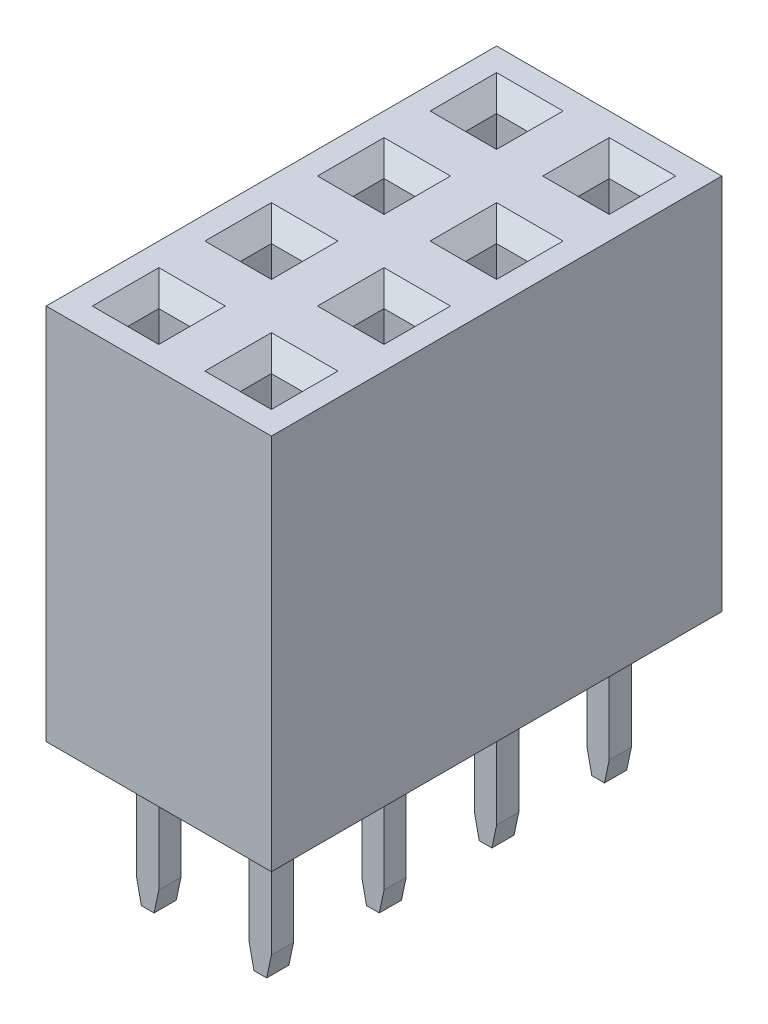
from build123d import *
from OCP.BRepFilletAPI import BRepFilletAPI_MakeChamfer

# Parameters (mm, degrees)
SKETCH_1_W                          = 2.54
SKETCH_1_H                          = 2.54
EXTRUDE_1_DEPTH                     = 8.51
SKETCH_4_W                          = 0.7
SKETCH_4_H                          = 0.7
CUT_EXTRUDE_1_DEPTH                 = 8.21
CHAMFER_3_SIZE                      = 0.4
SKETCH_2_W                          = 0.5
SKETCH_2_H                          = 0.5
EXTRUDE_2_DEPTH                     = 3.15
CHAMFER_2_SIZE                      = 0.5
CHAMFER_2_SIZE2                     = 0.106278281
PATTERN_LINEAR_1_COUNT              = 4
PATTERN_LINEAR_1_PITCH              = 2.54
PATTERN_LINEAR_1_COUNT_DIR2         = 2
PATTERN_LINEAR_1_PITCH_DIR2         = 2.54
CHAMFER_3_OF_PATTERN_LINEAR_1_SIZE  = 0.4
CHAMFER_2_OF_PATTERN_LINEAR_1_SIZE  = 0.5
CHAMFER_2_OF_PATTERN_LINEAR_1_SIZE2 = 0.106278281


with BuildPart() as part:
    # Эскиз1 → Бобышка-Вытянуть1 (new body)
    with BuildSketch(Plane(origin=(0, 0, 0), x_dir=(-1, 0, 0), z_dir=(0, 1, 0))):
        Rectangle(SKETCH_1_W, SKETCH_1_H)
    extrude_1 = extrude(amount=EXTRUDE_1_DEPTH)

    # Эскиз4 → Вырез-Вытянуть1 (cut)
    with BuildSketch(Plane(origin=(0, 8.51, 0), x_dir=(1, 0, 0), z_dir=(0, 1, 0))):
        Rectangle(SKETCH_4_W, SKETCH_4_H)
    cut_extrude_1 = extrude(amount=-CUT_EXTRUDE_1_DEPTH, mode=Mode.SUBTRACT)

    # Фаска3
    chamfer_3_edges = [part.edges().sort_by_distance(p)[0] for p in [
        (-0.35, 8.51, 0),
        (0, 8.51, 0.35),
        (0.35, 8.51, 0),
        (0, 8.51, -0.35),
    ]]
    chamfer(chamfer_3_edges, length=CHAMFER_3_SIZE)

    # Эскиз2 → Бобышка-Вытянуть2 (add)
    with BuildSketch(Plane(origin=(0, 0, 0), x_dir=(-1, 0, 0), z_dir=(0, 1, 0))):
        Rectangle(SKETCH_2_W, SKETCH_2_H)
    extrude_2 = extrude(amount=-EXTRUDE_2_DEPTH)

    # Фаска2: one chamfer whose edges measure the first distance from different faces: ONE call of the kernel's chamfer builder (chamfer() names one face for all edges)
    chamfer_2_edges_1 = [part.edges().sort_by_distance(p)[0] for p in [
        (-0.25, -3.15, 0),
    ]]
    chamfer_2_side_1 = [part.faces().sort_by_distance(p)[0] for p in [
        (-0.25, -1.575, 0),
    ]]
    chamfer_2_edges_2 = [part.edges().sort_by_distance(p)[0] for p in [
        (0.25, -3.15, 0),
    ]]
    chamfer_2_side_2 = [part.faces().sort_by_distance(p)[0] for p in [
        (0.25, -1.575, 0),
    ]]
    chamfer_2 = BRepFilletAPI_MakeChamfer(part.part.solid().wrapped)
    for e in chamfer_2_edges_1:
        chamfer_2.Add(CHAMFER_2_SIZE, CHAMFER_2_SIZE2, e.wrapped, chamfer_2_side_1[0].wrapped)  # the first distance lies on this face
    for e in chamfer_2_edges_2:
        chamfer_2.Add(CHAMFER_2_SIZE, CHAMFER_2_SIZE2, e.wrapped, chamfer_2_side_2[0].wrapped)  # the first distance lies on this face
    add(Compound.cast(chamfer_2.Shape()), mode=Mode.REPLACE)

    # Линейный массив1: Бобышка-Вытянуть1, Вырез-Вытянуть1, Extrude 2 4 × 2
    with Locations(*[(-j * PATTERN_LINEAR_1_PITCH_DIR2, 0, -i * PATTERN_LINEAR_1_PITCH) for i in range(PATTERN_LINEAR_1_COUNT) for j in range(PATTERN_LINEAR_1_COUNT_DIR2) if (i, j) != (0, 0)]):
        add(extrude_1)
        add(cut_extrude_1, mode=Mode.SUBTRACT)
        add(extrude_2)

    # Фаска3 of Линейный массив1
    chamfer_3_of_pattern_linear_1_edges = [part.edges().sort_by_distance(p)[0] for p in [
        (-2.89, 8.51, 0),
        (-2.54, 8.51, 0.35),
        (-2.19, 8.51, 0),
        (-2.54, 8.51, -0.35),
        (-0.35, 8.51, -2.54),
        (0, 8.51, -2.19),
        (0.35, 8.51, -2.54),
        (0, 8.51, -2.89),
        (-2.89, 8.51, -2.54),
        (-2.54, 8.51, -2.19),
        (-2.19, 8.51, -2.54),
        (-2.54, 8.51, -2.89),
        (-0.35, 8.51, -5.08),
        (0, 8.51, -4.73),
        (0.35, 8.51, -5.08),
        (0, 8.51, -5.43),
        (-2.89, 8.51, -5.08),
        (-2.54, 8.51, -4.73),
        (-2.19, 8.51, -5.08),
        (-2.54, 8.51, -5.43),
        (-0.35, 8.51, -7.62),
        (0, 8.51, -7.27),
        (0.35, 8.51, -7.62),
        (0, 8.51, -7.97),
        (-2.89, 8.51, -7.62),
        (-2.54, 8.51, -7.27),
        (-2.19, 8.51, -7.62),
        (-2.54, 8.51, -7.97),
    ]]
    chamfer(chamfer_3_of_pattern_linear_1_edges, length=CHAMFER_3_OF_PATTERN_LINEAR_1_SIZE)

    # Фаска2 of Линейный массив1: one chamfer whose edges measure the first distance from different faces: ONE call of the kernel's chamfer builder (chamfer() names one face for all edges)
    chamfer_2_of_pattern_linear_1_edges_1 = [part.edges().sort_by_distance(p)[0] for p in [
        (-2.79, -3.15, 0),
    ]]
    chamfer_2_of_pattern_linear_1_side_1 = [part.faces().sort_by_distance(p)[0] for p in [
        (-2.79, -1.575, 0),
    ]]
    chamfer_2_of_pattern_linear_1_edges_2 = [part.edges().sort_by_distance(p)[0] for p in [
        (-2.29, -3.15, 0),
    ]]
    chamfer_2_of_pattern_linear_1_side_2 = [part.faces().sort_by_distance(p)[0] for p in [
        (-2.29, -1.575, 0),
    ]]
    chamfer_2_of_pattern_linear_1_edges_3 = [part.edges().sort_by_distance(p)[0] for p in [
        (-0.25, -3.15, -2.54),
    ]]
    chamfer_2_of_pattern_linear_1_side_3 = [part.faces().sort_by_distance(p)[0] for p in [
        (-0.25, -1.575, -2.54),
    ]]
    chamfer_2_of_pattern_linear_1_edges_4 = [part.edges().sort_by_distance(p)[0] for p in [
        (0.25, -3.15, -2.54),
    ]]
    chamfer_2_of_pattern_linear_1_side_4 = [part.faces().sort_by_distance(p)[0] for p in [
        (0.25, -1.575, -2.54),
    ]]
    chamfer_2_of_pattern_linear_1_edges_5 = [part.edges().sort_by_distance(p)[0] for p in [
        (-2.79, -3.15, -2.54),
    ]]
    chamfer_2_of_pattern_linear_1_side_5 = [part.faces().sort_by_distance(p)[0] for p in [
        (-2.79, -1.575, -2.54),
    ]]
    chamfer_2_of_pattern_linear_1_edges_6 = [part.edges().sort_by_distance(p)[0] for p in [
        (-2.29, -3.15, -2.54),
    ]]
    chamfer_2_of_pattern_linear_1_side_6 = [part.faces().sort_by_distance(p)[0] for p in [
        (-2.29, -1.575, -2.54),
    ]]
    chamfer_2_of_pattern_linear_1_edges_7 = [part.edges().sort_by_distance(p)[0] for p in [
        (-0.25, -3.15, -5.08),
    ]]
    chamfer_2_of_pattern_linear_1_side_7 = [part.faces().sort_by_distance(p)[0] for p in [
        (-0.25, -1.575, -5.08),
    ]]
    chamfer_2_of_pattern_linear_1_edges_8 = [part.edges().sort_by_distance(p)[0] for p in [
        (0.25, -3.15, -5.08),
    ]]
    chamfer_2_of_pattern_linear_1_side_8 = [part.faces().sort_by_distance(p)[0] for p in [
        (0.25, -1.575, -5.08),
    ]]
    chamfer_2_of_pattern_linear_1_edges_9 = [part.edges().sort_by_distance(p)[0] for p in [
        (-2.79, -3.15, -5.08),
    ]]
    chamfer_2_of_pattern_linear_1_side_9 = [part.faces().sort_by_distance(p)[0] for p in [
        (-2.79, -1.575, -5.08),
    ]]
    chamfer_2_of_pattern_linear_1_edges_10 = [part.edges().sort_by_distance(p)[0] for p in [
        (-2.29, -3.15, -5.08),
    ]]
    chamfer_2_of_pattern_linear_1_side_10 = [part.faces().sort_by_distance(p)[0] for p in [
        (-2.29, -1.575, -5.08),
    ]]
    chamfer_2_of_pattern_linear_1_edges_11 = [part.edges().sort_by_distance(p)[0] for p in [
        (-0.25, -3.15, -7.62),
    ]]
    chamfer_2_of_pattern_linear_1_side_11 = [part.faces().sort_by_distance(p)[0] for p in [
        (-0.25, -1.575, -7.62),
    ]]
    chamfer_2_of_pattern_linear_1_edges_12 = [part.edges().sort_by_distance(p)[0] for p in [
        (0.25, -3.15, -7.62),
    ]]
    chamfer_2_of_pattern_linear_1_side_12 = [part.faces().sort_by_distance(p)[0] for p in [
        (0.25, -1.575, -7.62),
    ]]
    chamfer_2_of_pattern_linear_1_edges_13 = [part.edges().sort_by_distance(p)[0] for p in [
        (-2.79, -3.15, -7.62),
    ]]
    chamfer_2_of_pattern_linear_1_side_13 = [part.faces().sort_by_distance(p)[0] for p in [
        (-2.79, -1.575, -7.62),
    ]]
    chamfer_2_of_pattern_linear_1_edges_14 = [part.edges().sort_by_distance(p)[0] for p in [
        (-2.29, -3.15, -7.62),
    ]]
    chamfer_2_of_pattern_linear_1_side_14 = [part.faces().sort_by_distance(p)[0] for p in [
        (-2.29, -1.575, -7.62),
    ]]
    chamfer_2_of_pattern_linear_1 = BRepFilletAPI_MakeChamfer(part.part.solid().wrapped)
    for e in chamfer_2_of_pattern_linear_1_edges_1:
        chamfer_2_of_pattern_linear_1.Add(CHAMFER_2_OF_PATTERN_LINEAR_1_SIZE, CHAMFER_2_OF_PATTERN_LINEAR_1_SIZE2, e.wrapped, chamfer_2_of_pattern_linear_1_side_1[0].wrapped)  # the first distance lies on this face
    for e in chamfer_2_of_pattern_linear_1_edges_2:
        chamfer_2_of_pattern_linear_1.Add(CHAMFER_2_OF_PATTERN_LINEAR_1_SIZE, CHAMFER_2_OF_PATTERN_LINEAR_1_SIZE2, e.wrapped, chamfer_2_of_pattern_linear_1_side_2[0].wrapped)  # the first distance lies on this face
    for e in chamfer_2_of_pattern_linear_1_edges_3:
        chamfer_2_of_pattern_linear_1.Add(CHAMFER_2_OF_PATTERN_LINEAR_1_SIZE, CHAMFER_2_OF_PATTERN_LINEAR_1_SIZE2, e.wrapped, chamfer_2_of_pattern_linear_1_side_3[0].wrapped)  # the first distance lies on this face
    for e in chamfer_2_of_pattern_linear_1_edges_4:
        chamfer_2_of_pattern_linear_1.Add(CHAMFER_2_OF_PATTERN_LINEAR_1_SIZE, CHAMFER_2_OF_PATTERN_LINEAR_1_SIZE2, e.wrapped, chamfer_2_of_pattern_linear_1_side_4[0].wrapped)  # the first distance lies on this face
    for e in chamfer_2_of_pattern_linear_1_edges_5:
        chamfer_2_of_pattern_linear_1.Add(CHAMFER_2_OF_PATTERN_LINEAR_1_SIZE, CHAMFER_2_OF_PATTERN_LINEAR_1_SIZE2, e.wrapped, chamfer_2_of_pattern_linear_1_side_5[0].wrapped)  # the first distance lies on this face
    for e in chamfer_2_of_pattern_linear_1_edges_6:
        chamfer_2_of_pattern_linear_1.Add(CHAMFER_2_OF_PATTERN_LINEAR_1_SIZE, CHAMFER_2_OF_PATTERN_LINEAR_1_SIZE2, e.wrapped, chamfer_2_of_pattern_linear_1_side_6[0].wrapped)  # the first distance lies on this face
    for e in chamfer_2_of_pattern_linear_1_edges_7:
        chamfer_2_of_pattern_linear_1.Add(CHAMFER_2_OF_PATTERN_LINEAR_1_SIZE, CHAMFER_2_OF_PATTERN_LINEAR_1_SIZE2, e.wrapped, chamfer_2_of_pattern_linear_1_side_7[0].wrapped)  # the first distance lies on this face
    for e in chamfer_2_of_pattern_linear_1_edges_8:
        chamfer_2_of_pattern_linear_1.Add(CHAMFER_2_OF_PATTERN_LINEAR_1_SIZE, CHAMFER_2_OF_PATTERN_LINEAR_1_SIZE2, e.wrapped, chamfer_2_of_pattern_linear_1_side_8[0].wrapped)  # the first distance lies on this face
    for e in chamfer_2_of_pattern_linear_1_edges_9:
        chamfer_2_of_pattern_linear_1.Add(CHAMFER_2_OF_PATTERN_LINEAR_1_SIZE, CHAMFER_2_OF_PATTERN_LINEAR_1_SIZE2, e.wrapped, chamfer_2_of_pattern_linear_1_side_9[0].wrapped)  # the first distance lies on this face
    for e in chamfer_2_of_pattern_linear_1_edges_10:
        chamfer_2_of_pattern_linear_1.Add(CHAMFER_2_OF_PATTERN_LINEAR_1_SIZE, CHAMFER_2_OF_PATTERN_LINEAR_1_SIZE2, e.wrapped, chamfer_2_of_pattern_linear_1_side_10[0].wrapped)  # the first distance lies on this face
    for e in chamfer_2_of_pattern_linear_1_edges_11:
        chamfer_2_of_pattern_linear_1.Add(CHAMFER_2_OF_PATTERN_LINEAR_1_SIZE, CHAMFER_2_OF_PATTERN_LINEAR_1_SIZE2, e.wrapped, chamfer_2_of_pattern_linear_1_side_11[0].wrapped)  # the first distance lies on this face
    for e in chamfer_2_of_pattern_linear_1_edges_12:
        chamfer_2_of_pattern_linear_1.Add(CHAMFER_2_OF_PATTERN_LINEAR_1_SIZE, CHAMFER_2_OF_PATTERN_LINEAR_1_SIZE2, e.wrapped, chamfer_2_of_pattern_linear_1_side_12[0].wrapped)  # the first distance lies on this face
    for e in chamfer_2_of_pattern_linear_1_edges_13:
        chamfer_2_of_pattern_linear_1.Add(CHAMFER_2_OF_PATTERN_LINEAR_1_SIZE, CHAMFER_2_OF_PATTERN_LINEAR_1_SIZE2, e.wrapped, chamfer_2_of_pattern_linear_1_side_13[0].wrapped)  # the first distance lies on this face
    for e in chamfer_2_of_pattern_linear_1_edges_14:
        chamfer_2_of_pattern_linear_1.Add(CHAMFER_2_OF_PATTERN_LINEAR_1_SIZE, CHAMFER_2_OF_PATTERN_LINEAR_1_SIZE2, e.wrapped, chamfer_2_of_pattern_linear_1_side_14[0].wrapped)  # the first distance lies on this face
    add(Compound.cast(chamfer_2_of_pattern_linear_1.Shape()), mode=Mode.REPLACE)


solid = part.part
